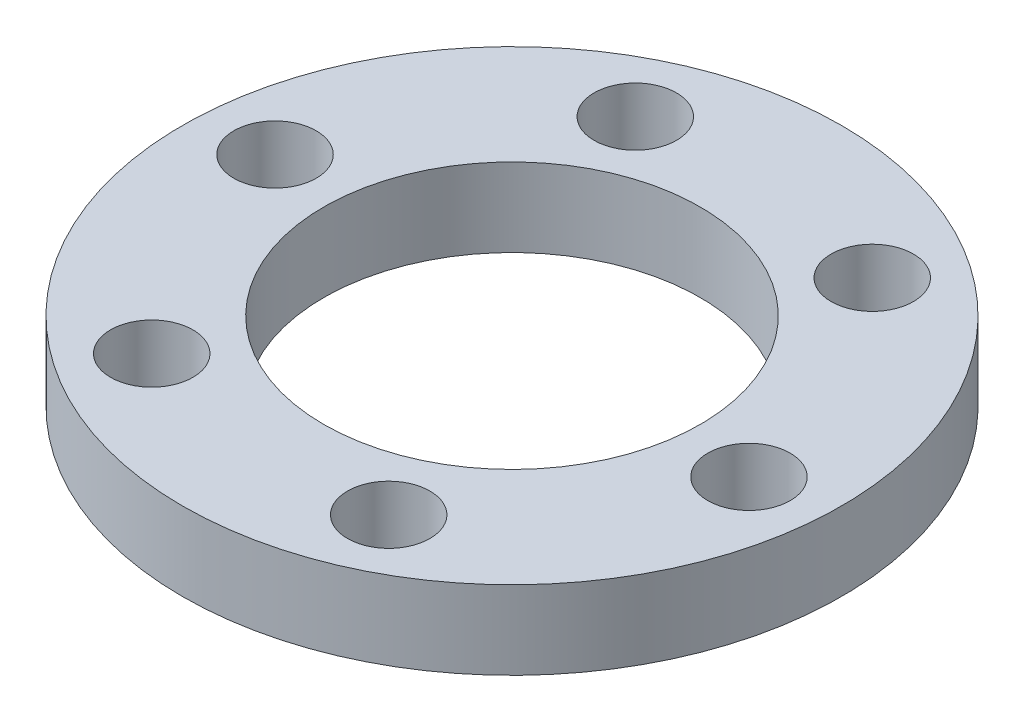
from build123d import *

# Parameters (mm, degrees)
SKETCH1_R           = 21
SKETCH1_R_2         = 12
SKETCH1_R_3         = 2.625
BOSS_EXTRUDE1_DEPTH = 5


with BuildPart() as part:
    # Sketch1 → Boss-Extrude1 (new body)
    with BuildSketch(Plane(origin=(0, 0, 0), x_dir=(1, 0, 0), z_dir=(0, 1, 0))):
        Circle(SKETCH1_R)
        Circle(SKETCH1_R_2, mode=Mode.SUBTRACT)
        with Locations((-16.44510387, 1.344826642)):
            Circle(SKETCH1_R_3, mode=Mode.SUBTRACT)
        with Locations((-7.0578979, 14.91429104)):
            Circle(SKETCH1_R_3, mode=Mode.SUBTRACT)
        with Locations((9.387205971, 13.569464399)):
            Circle(SKETCH1_R_3, mode=Mode.SUBTRACT)
        with Locations((16.44510387, -1.344826642)):
            Circle(SKETCH1_R_3, mode=Mode.SUBTRACT)
        with Locations((7.0578979, -14.91429104)):
            Circle(SKETCH1_R_3, mode=Mode.SUBTRACT)
        with Locations((-9.387205971, -13.569464399)):
            Circle(SKETCH1_R_3, mode=Mode.SUBTRACT)
    extrude(amount=BOSS_EXTRUDE1_DEPTH)


solid = part.part
